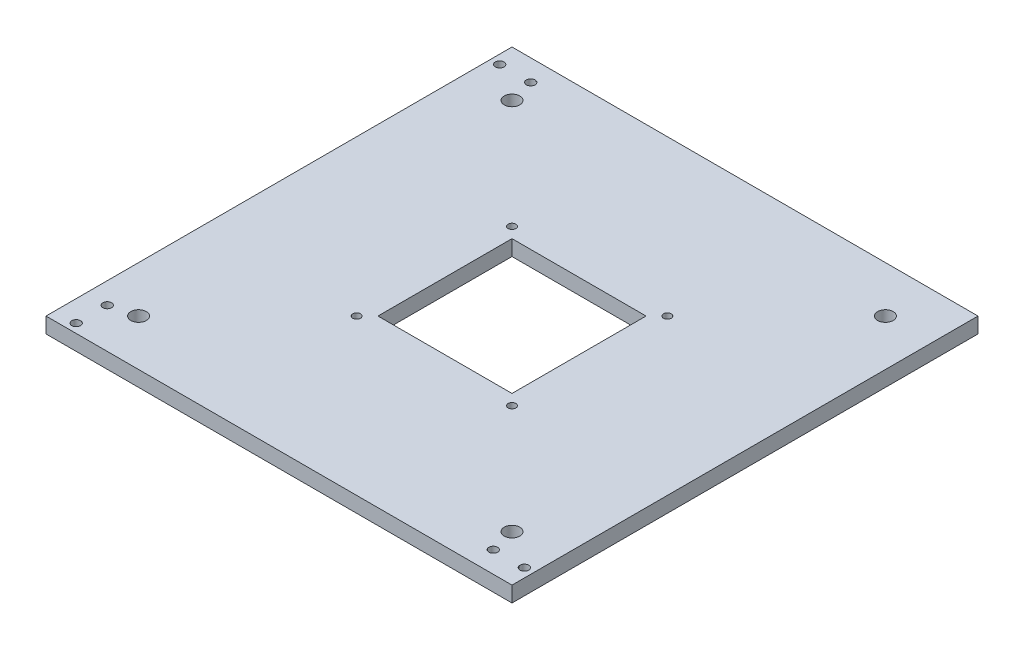
from build123d import *

# Parameters (mm, degrees)
SKETCH1_W           = 190.5
SKETCH1_H           = 190.5
SKETCH1_R           = 1.905
SKETCH1_R_2         = 1.778
BOSS_EXTRUDE1_DEPTH = 6.35
SKETCH2_W           = 54.8
SKETCH2_H           = 54.8
CUT_EXTRUDE4_DEPTH  = 10
SKETCH4_R           = 1.5875
CUT_EXTRUDE5_DEPTH  = 10
SKETCH5_R           = 3.175
CUT_EXTRUDE6_DEPTH  = 7.35


with BuildPart() as part:
    # Sketch1 → Boss-Extrude1 (new body)
    with BuildSketch(Plane(origin=(0, 0, 0), x_dir=(1, 0, 0), z_dir=(0, 1, 0))):
        Rectangle(SKETCH1_W, SKETCH1_H)
        with Locations((-11.303, 11.303)):
            Circle(SKETCH1_R, mode=Mode.SUBTRACT)
        with Locations((-11.303, -11.303)):
            Circle(SKETCH1_R, mode=Mode.SUBTRACT)
        with Locations((11.303, 11.303)):
            Circle(SKETCH1_R, mode=Mode.SUBTRACT)
        with Locations((11.303, -11.303)):
            Circle(SKETCH1_R, mode=Mode.SUBTRACT)
        with Locations((-78.9, 86.55)):
            Circle(SKETCH1_R_2, mode=Mode.SUBTRACT)
        with Locations((-91.6, 86.55)):
            Circle(SKETCH1_R_2, mode=Mode.SUBTRACT)
        with Locations((91.6, -86.55)):
            Circle(SKETCH1_R_2, mode=Mode.SUBTRACT)
        with Locations((78.9, -86.55)):
            Circle(SKETCH1_R_2, mode=Mode.SUBTRACT)
        with Locations((-86.55, -78.9)):
            Circle(SKETCH1_R_2, mode=Mode.SUBTRACT)
        with Locations((-86.55, -91.6)):
            Circle(SKETCH1_R_2, mode=Mode.SUBTRACT)
    extrude(amount=BOSS_EXTRUDE1_DEPTH)

    # Sketch2 → Cut-Extrude4 (cut)
    with BuildSketch(Plane.XZ):
        Rectangle(SKETCH2_W, SKETCH2_H)
    extrude(amount=-CUT_EXTRUDE4_DEPTH, mode=Mode.SUBTRACT)

    # Sketch4 → Cut-Extrude5 (cut)
    with BuildSketch(Plane.XZ):
        with Locations((-31.75, 31.75)):
            Circle(SKETCH4_R)
        with Locations((31.75, 31.75)):
            Circle(SKETCH4_R)
        with Locations((31.75, -31.75)):
            Circle(SKETCH4_R)
        with Locations((-31.75, -31.75)):
            Circle(SKETCH4_R)
    extrude(amount=-CUT_EXTRUDE5_DEPTH, mode=Mode.SUBTRACT)

    # Sketch5 → Cut-Extrude6 (cut, through all)
    with BuildSketch(Plane.XZ):
        with Locations((76.33, -76.33)):
            Circle(SKETCH5_R)
        with Locations((76.33, 76.33)):
            Circle(SKETCH5_R)
        with Locations((-76.33, -76.33)):
            Circle(SKETCH5_R)
        with Locations((-76.33, 76.33)):
            Circle(SKETCH5_R)
    extrude(amount=-CUT_EXTRUDE6_DEPTH, mode=Mode.SUBTRACT)


solid = part.part
